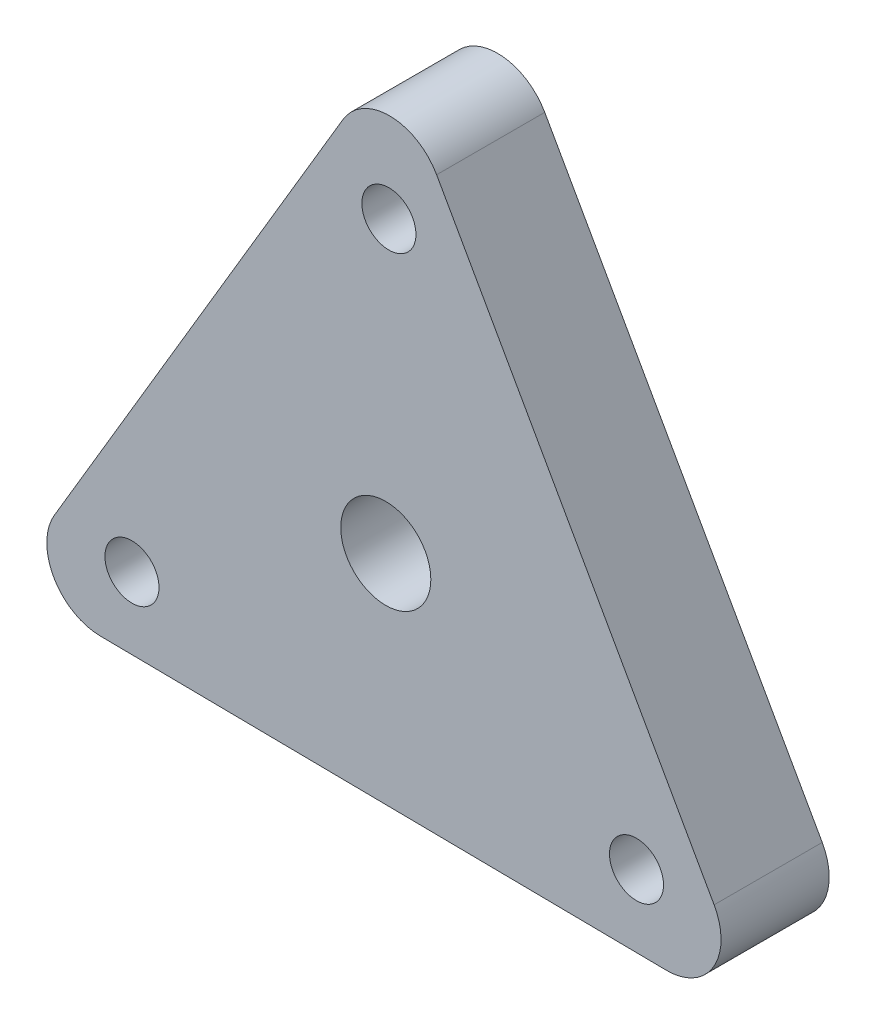
from build123d import *

# Parameters (mm, degrees)
SKETCH1_R           = 1.5
SKETCH1_R_2         = 2.5
BOSS_EXTRUDE2_DEPTH = 6
FILLET1_R           = 3


with BuildPart() as part:
    # Sketch1 → Boss-Extrude2 (new body)
    with BuildSketch(Plane.XY):
        Polygon((20.766769668, -12.307033049), (0.274818432, 24.138066612), (-21.0415881, -11.831033562), align=None)
        with Locations((0.173413232, 16.164877395)):
            Circle(SKETCH1_R, mode=Mode.SUBTRACT)
        with Locations((13.912487857, -8.232618961)):
            Circle(SKETCH1_R, mode=Mode.SUBTRACT)
        with Locations((-14.085901089, -7.932258433)):
            Circle(SKETCH1_R, mode=Mode.SUBTRACT)
        Circle(SKETCH1_R_2, mode=Mode.SUBTRACT)
    extrude(amount=BOSS_EXTRUDE2_DEPTH)

    # Fillet1
    fillet1_edges = [part.edges().sort_by_distance(p)[0] for p in [
        (0.274818432, 24.138066612, 3),
        (20.766769668, -12.307033049, 3),
        (-21.0415881, -11.831033562, 3),
    ]]
    fillet(fillet1_edges, radius=FILLET1_R)


solid = part.part
